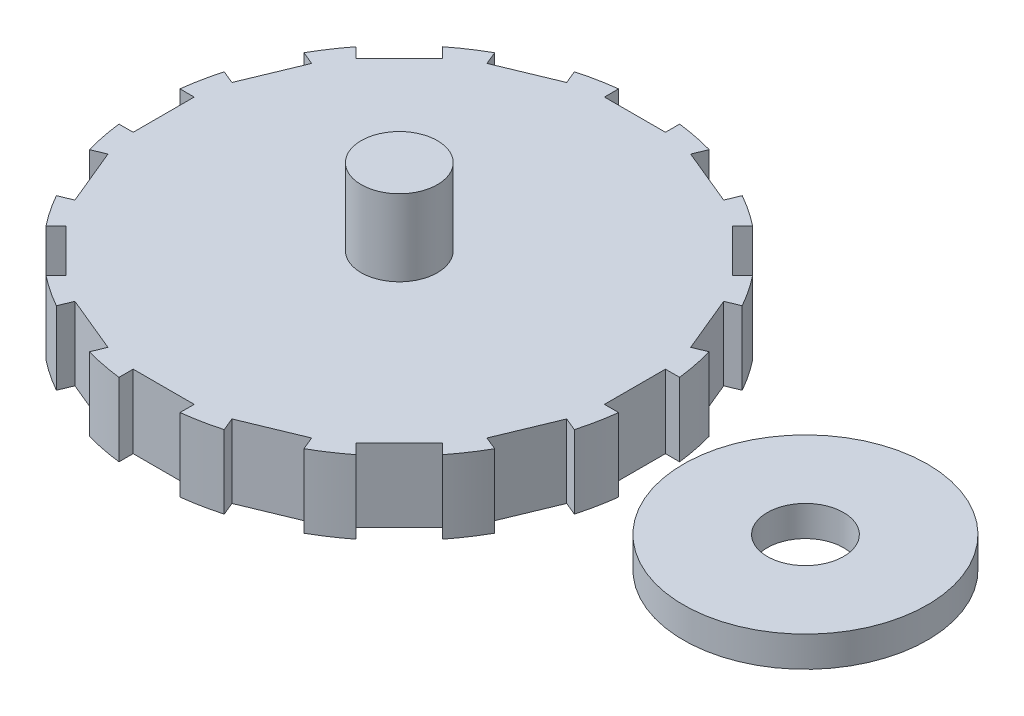
from build123d import *

# Parameters (mm, degrees)
SKETCH1_R           = 8.25
BOSS_EXTRUDE1_DEPTH = 2.4
SKETCH2_R           = 1.25
BOSS_EXTRUDE2_DEPTH = 2.5
SKETCH4_W           = 2
SKETCH4_H           = 1.552029397
SKETCH4_W_2         = 1.552029397
SKETCH4_H_2         = 2
CUT_EXTRUDE2_DEPTH  = 4
SKETCH5_R           = 4
SKETCH5_R_2         = 1.25
BOSS_EXTRUDE3_DEPTH = 1


with BuildPart() as part:
    # Sketch1 → Boss-Extrude1 (new body)
    with BuildSketch(Plane(origin=(0, 0, 0), x_dir=(1, 0, 0), z_dir=(0, 1, 0))):
        Circle(SKETCH1_R)
    extrude(amount=BOSS_EXTRUDE1_DEPTH)

    # Sketch2 → Boss-Extrude2 (add)
    with BuildSketch(Plane(origin=(0, 2.4, 0), x_dir=(1, 0, 0), z_dir=(0, 1, 0))):
        Circle(SKETCH2_R)
    extrude(amount=BOSS_EXTRUDE2_DEPTH)

    # Sketch4 → Cut-Extrude2 (cut)
    with BuildSketch(Plane.XZ):
        Polygon((2.625964421, 8.952764849), (2.032028484, 7.518876655), (3.879787549, 6.75350979), (4.473723486, 8.187397984), align=None)
        with Locations((0, 8.500174583)):
            Rectangle(SKETCH4_W, SKETCH4_H)
        Polygon((5.852149563, 7.266363125), (4.754699052, 6.168912614), (6.168912614, 4.754699052), (7.266363125, 5.852149563), align=None)
        Polygon((8.187397984, 4.473723486), (6.75350979, 3.879787549), (7.518876655, 2.032028484), (8.952764849, 2.625964421), align=None)
        with Locations((8.500174583, 0)):
            Rectangle(SKETCH4_W_2, SKETCH4_H_2)
        Polygon((8.952764849, -2.625964421), (7.518876655, -2.032028484), (6.75350979, -3.879787549), (8.187397984, -4.473723486), align=None)
        Polygon((7.266363125, -5.852149563), (6.168912614, -4.754699052), (4.754699052, -6.168912614), (5.852149563, -7.266363125), align=None)
        Polygon((4.473723486, -8.187397984), (3.879787549, -6.75350979), (2.032028484, -7.518876655), (2.625964421, -8.952764849), align=None)
        with Locations((0, -8.500174583)):
            Rectangle(SKETCH4_W, SKETCH4_H)
        Polygon((-2.625964421, -8.952764849), (-2.032028484, -7.518876655), (-3.879787549, -6.75350979), (-4.473723486, -8.187397984), align=None)
        Polygon((-5.852149563, -7.266363125), (-4.754699052, -6.168912614), (-6.168912614, -4.754699052), (-7.266363125, -5.852149563), align=None)
        Polygon((-8.187397984, -4.473723486), (-6.75350979, -3.879787549), (-7.518876655, -2.032028484), (-8.952764849, -2.625964421), align=None)
        with Locations((-8.500174583, 0)):
            Rectangle(SKETCH4_W_2, SKETCH4_H_2)
        Polygon((-8.952764849, 2.625964421), (-7.518876655, 2.032028484), (-6.75350979, 3.879787549), (-8.187397984, 4.473723486), align=None)
        Polygon((-7.266363125, 5.852149563), (-6.168912614, 4.754699052), (-4.754699052, 6.168912614), (-5.852149563, 7.266363125), align=None)
        Polygon((-4.473723486, 8.187397984), (-3.879787549, 6.75350979), (-2.032028484, 7.518876655), (-2.625964421, 8.952764849), align=None)
    extrude(amount=-CUT_EXTRUDE2_DEPTH, mode=Mode.SUBTRACT)


with BuildPart() as body_2:
    # Sketch5 → Boss-Extrude3 (new body)
    with BuildSketch(Plane.XZ):
        with Locations((13.313340445, 0)):
            Circle(SKETCH5_R)
        with Locations((13.313340445, 0)):
            Circle(SKETCH5_R_2, mode=Mode.SUBTRACT)
    extrude(amount=-BOSS_EXTRUDE3_DEPTH)


solid = Compound([part.part, body_2.part])
